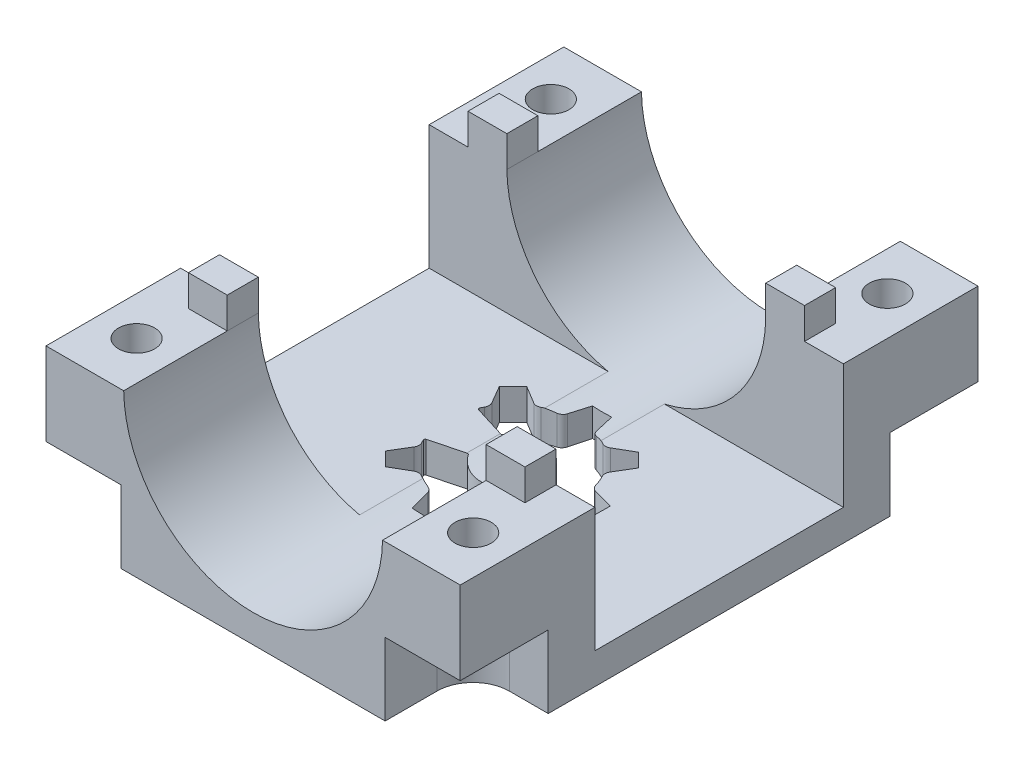
from build123d import *

# Parameters (mm, degrees)
CROQUIS1_W              = 40
CROQUIS1_H              = 50
SALIENTE_EXTRUIR1_DEPTH = 20
CROQUIS2_R              = 12.5
CORTAR_EXTRUIR1_DEPTH   = 51
CROQUIS3_R              = 1.75
CORTAR_EXTRUIR2_DEPTH   = 21
CORTAR_EXTRUIR3_DEPTH   = 41
CROQUIS5_W              = 3.750800051
CROQUIS5_H              = 3
SALIENTE_EXTRUIR3_DEPTH = 3
CORTAR_EXTRUIR5_DEPTH   = 24
CORTAR_EXTRUIR6_DEPTH   = 12
CROQUIS8_W              = 40
CROQUIS8_H              = 50
CORTAR_EXTRUIR7_DEPTH   = 5


with BuildPart() as part:
    # Croquis1 → Saliente-Extruir1 (new body)
    with BuildSketch(Plane(origin=(0, 0, 0), x_dir=(1, 0, 0), z_dir=(0, 1, 0))):
        with Locations((20, 25)):
            Rectangle(CROQUIS1_W, CROQUIS1_H)
    extrude(amount=SALIENTE_EXTRUIR1_DEPTH)

    # Croquis2 → Cortar-Extruir1 (cut, through all)
    with BuildSketch(Plane.XY):
        with Locations((20, 20.2)):
            Circle(CROQUIS2_R)
    extrude(amount=-CORTAR_EXTRUIR1_DEPTH, mode=Mode.SUBTRACT)

    # Croquis3 → Cortar-Extruir2 (cut, through all)
    with BuildSketch(Plane(origin=(0, 20, 0), x_dir=(1, 0, 0), z_dir=(0, 1, 0))):
        with Locations((3.75, 45)):
            Circle(CROQUIS3_R)
        with Locations((36.25, 45)):
            Circle(CROQUIS3_R)
        with Locations((36.25, 5)):
            Circle(CROQUIS3_R)
        with Locations((3.75, 5)):
            Circle(CROQUIS3_R)
    extrude(amount=-CORTAR_EXTRUIR2_DEPTH, mode=Mode.SUBTRACT)

    # Croquis4 → Cortar-Extruir3 (cut, through all)
    with BuildSketch(Plane(origin=(40, 0, 0), x_dir=(0, 0, -1), z_dir=(1, 0, 0))):
        Polygon((25, 20), (37, 20), (37, 8), (13, 8), (13, 20), align=None)
    extrude(amount=-CORTAR_EXTRUIR3_DEPTH, mode=Mode.SUBTRACT)

    # Croquis5 → Saliente-Extruir3 (add)
    with BuildSketch(Plane(origin=(0, 20, 0), x_dir=(1, 0, 0), z_dir=(0, 1, 0))):
        with Locations((5.626200076, 38.5)):
            Rectangle(CROQUIS5_W, CROQUIS5_H)
        with Locations((34.373799924, 11.5)):
            Rectangle(CROQUIS5_W, CROQUIS5_H)
        with Locations((34.373799924, 38.5)):
            Rectangle(CROQUIS5_W, CROQUIS5_H)
        with Locations((5.626200076, 11.5)):
            Rectangle(CROQUIS5_W, CROQUIS5_H)
    extrude(amount=SALIENTE_EXTRUIR3_DEPTH)

    # Croquis6 → Cortar-Extruir5 (cut, through all)
    with BuildSketch(Plane.XZ):
        with BuildLine():
            Line((13.188139939, -19.615331161), (14.501537669, -18.279657152))
            Line((14.501537669, -18.279657152), (16.224863288, -19.28260268))
            ThreePointArc((16.224863288, -19.28260268), (16.575067996, -19.380217097), (16.928320792, -19.294284721))
            ThreePointArc((16.928320792, -19.294284721), (17.469957789, -19.034324312), (18.033343063, -18.825644933))
            ThreePointArc((18.033343063, -18.825644933), (18.340671144, -18.631425053), (18.513928995, -18.31181024))
            Line((18.513928995, -18.31181024), (18.990823409, -16.375751708))
            Line((18.990823409, -16.375751708), (20.864, -16.36))
            Line((20.864, -16.36), (21.373385647, -18.287764816))
            ThreePointArc((21.373385647, -18.287764816), (21.551993955, -18.604420755), (21.862544768, -18.793444837))
            ThreePointArc((21.862544768, -18.793444837), (22.429359729, -18.992620263), (22.975291881, -19.243435206))
            ThreePointArc((22.975291881, -19.243435206), (23.329939845, -19.323414782), (23.678453448, -19.219924782))
            Line((23.678453448, -19.219924782), (25.384668839, -18.188139939))
            Line((25.384668839, -18.188139939), (26.720342848, -19.501537669))
            Line((26.720342848, -19.501537669), (25.71739732, -21.224863288))
            ThreePointArc((25.71739732, -21.224863288), (25.619782903, -21.575067996), (25.705715279, -21.928320792))
            ThreePointArc((25.705715279, -21.928320792), (25.965675688, -22.469957789), (26.174355067, -23.033343063))
            ThreePointArc((26.174355067, -23.033343063), (26.368574947, -23.340671144), (26.68818976, -23.513928995))
            Line((26.68818976, -23.513928995), (28.624248292, -23.990823409))
            Line((28.624248292, -23.990823409), (28.64, -25.864))
            Line((28.64, -25.864), (26.712235184, -26.373385647))
            ThreePointArc((26.712235184, -26.373385647), (26.395579245, -26.551993955), (26.206555163, -26.862544768))
            ThreePointArc((26.206555163, -26.862544768), (26.007379737, -27.429359729), (25.756564794, -27.975291881))
            ThreePointArc((25.756564794, -27.975291881), (25.676585218, -28.329939845), (25.780075218, -28.678453448))
            Line((25.780075218, -28.678453448), (26.811860061, -30.384668839))
            Line((26.811860061, -30.384668839), (25.498462331, -31.720342848))
            Line((25.498462331, -31.720342848), (23.775136712, -30.71739732))
            ThreePointArc((23.775136712, -30.71739732), (23.424932004, -30.619782903), (23.071679208, -30.705715279))
            ThreePointArc((23.071679208, -30.705715279), (22.530042211, -30.965675688), (21.966656937, -31.174355067))
            ThreePointArc((21.966656937, -31.174355067), (21.659328856, -31.368574947), (21.486071005, -31.68818976))
            Line((21.486071005, -31.68818976), (21.009176591, -33.624248292))
            Line((21.009176591, -33.624248292), (19.136, -33.64))
            Line((19.136, -33.64), (18.626614353, -31.712235184))
            ThreePointArc((18.626614353, -31.712235184), (18.448006045, -31.395579245), (18.137455232, -31.206555163))
            ThreePointArc((18.137455232, -31.206555163), (17.570640271, -31.007379737), (17.024708119, -30.756564794))
            ThreePointArc((17.024708119, -30.756564794), (16.670060155, -30.676585218), (16.321546552, -30.780075218))
            Line((16.321546552, -30.780075218), (14.615331161, -31.811860061))
            Line((14.615331161, -31.811860061), (13.279657152, -30.498462331))
            Line((13.279657152, -30.498462331), (14.28260268, -28.775136712))
            ThreePointArc((14.28260268, -28.775136712), (14.380217097, -28.424932004), (14.294284721, -28.071679208))
            ThreePointArc((14.294284721, -28.071679208), (14.208247472, -27.906200724), (14.127008205, -27.738314697))
            ThreePointArc((14.127008205, -27.738314697), (14.125953752, -27.626452127), (14.209575503, -27.552143653))
            Line((14.209575503, -27.552143653), (17.384042323, -26.571445385))
            ThreePointArc((17.384042323, -26.571445385), (23.05159058, -25.021681648), (17.406635637, -23.391542216))
            Line((17.406635637, -23.391542216), (14.170602247, -22.54767412))
            ThreePointArc((14.170602247, -22.54767412), (14.082937198, -22.475491969), (14.08129489, -22.361945826))
            ThreePointArc((14.08129489, -22.361945826), (14.159930296, -22.19215637), (14.243435206, -22.024708119))
            ThreePointArc((14.243435206, -22.024708119), (14.323414782, -21.670060155), (14.219924782, -21.321546552))
            Line((14.219924782, -21.321546552), (13.188139939, -19.615331161))
        make_face()
    extrude(amount=-CORTAR_EXTRUIR5_DEPTH, mode=Mode.SUBTRACT)

    # Croquis7 → Cortar-Extruir6 (cut)
    with BuildSketch(Plane.XZ):
        with BuildLine():
            Line((7.25, -5), (7.25, 0))
            Line((7.25, 0), (0, 0))
            Line((0, 0), (0, -8.5))
            Line((0, -8.5), (3.75, -8.5))
            ThreePointArc((3.75, -8.5), (6.224873734, -7.474873734), (7.25, -5))
        make_face()
        with BuildLine():
            Line((32.75, -5), (32.75, 0))
            Line((32.75, 0), (40, 0))
            Line((40, 0), (40, -8.5))
            Line((40, -8.5), (36.25, -8.5))
            ThreePointArc((36.25, -8.5), (33.775126266, -7.474873734), (32.75, -5))
        make_face()
        with BuildLine():
            Line((36.25, -41.5), (40, -41.5))
            Line((40, -41.5), (40, -50))
            Line((40, -50), (32.75, -50))
            Line((32.75, -50), (32.75, -45))
            ThreePointArc((32.75, -45), (33.775126266, -42.525126266), (36.25, -41.5))
        make_face()
        with BuildLine():
            Line((7.25, -45), (7.25, -50))
            Line((7.25, -50), (0, -50))
            Line((0, -50), (0, -41.5))
            Line((0, -41.5), (3.75, -41.5))
            ThreePointArc((3.75, -41.5), (6.224873734, -42.525126266), (7.25, -45))
        make_face()
    extrude(amount=-CORTAR_EXTRUIR6_DEPTH, mode=Mode.SUBTRACT)

    # Croquis8 → Cortar-Extruir7 (cut)
    with BuildSketch(Plane.XZ):
        with Locations((20, -25)):
            Rectangle(CROQUIS8_W, CROQUIS8_H)
    extrude(amount=-CORTAR_EXTRUIR7_DEPTH, mode=Mode.SUBTRACT)


solid = part.part
